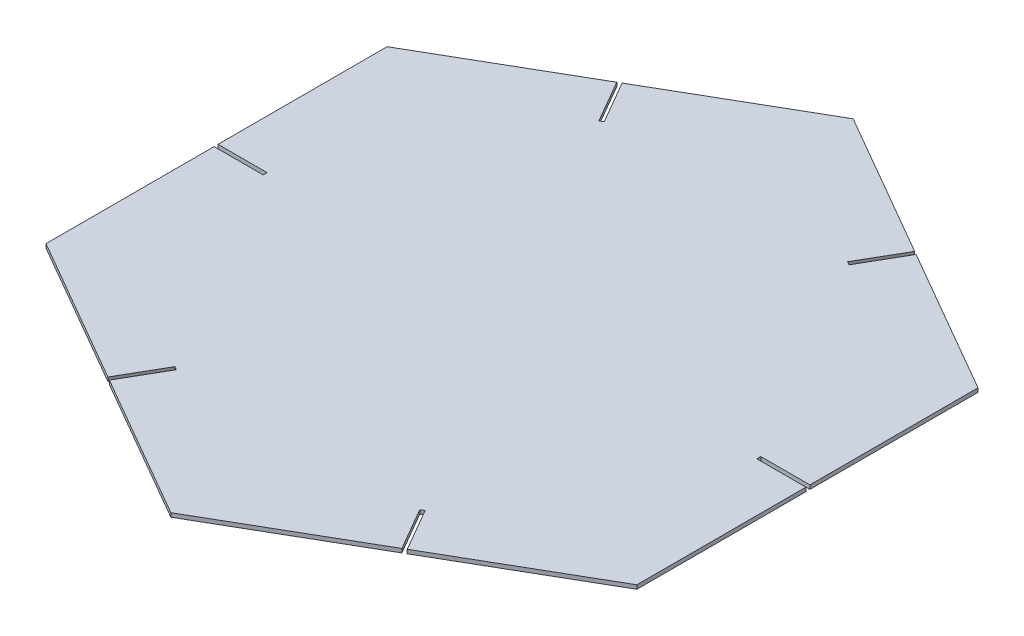
from build123d import *

# Parameters (mm, degrees)
BOSS_EXTRUDE1_DEPTH = 0.8
SKETCH3_W           = 10
SKETCH3_H           = 0.8
CUT_EXTRUDE1_DEPTH  = 1.8


with BuildPart() as part:
    # Sketch2 → Boss-Extrude1 (new body)
    with BuildSketch(Plane(origin=(0, 0, 0), x_dir=(1, 0, 0), z_dir=(0, 1, 0))):
        Polygon((0, 69.507859614), (-60.195572189, 34.753929807), (-60.195572189, -34.753929807), (0, -69.507859614), (60.195572189, -34.753929807), (60.195572189, 34.753929807), align=None)
    extrude(amount=BOSS_EXTRUDE1_DEPTH)

    # Sketch3 → Cut-Extrude1 (cut, through all)
    with BuildSketch(Plane.XZ):
        Polygon((29.664773392, -52.380894711), (24.664773392, -43.720640673), (25.357593716, -43.320640673), (30.357593716, -51.980894711), align=None)
        with Locations((55.195572189, -0.1)):
            Rectangle(SKETCH3_W, SKETCH3_H)
        Polygon((-30.530798796, -51.880894711), (-25.530798796, -43.220640673), (-24.837978473, -43.620640673), (-29.837978473, -52.280894711), align=None)
        with Locations((-55.195572189, 0.1)):
            Rectangle(SKETCH3_W, SKETCH3_H)
        Polygon((-29.664773392, 52.380894711), (-24.664773392, 43.720640673), (-25.357593716, 43.320640673), (-30.357593716, 51.980894711), align=None)
        Polygon((30.530798796, 51.880894711), (25.530798796, 43.220640673), (24.837978473, 43.620640673), (29.837978473, 52.280894711), align=None)
    extrude(amount=-CUT_EXTRUDE1_DEPTH, mode=Mode.SUBTRACT)


solid = part.part
